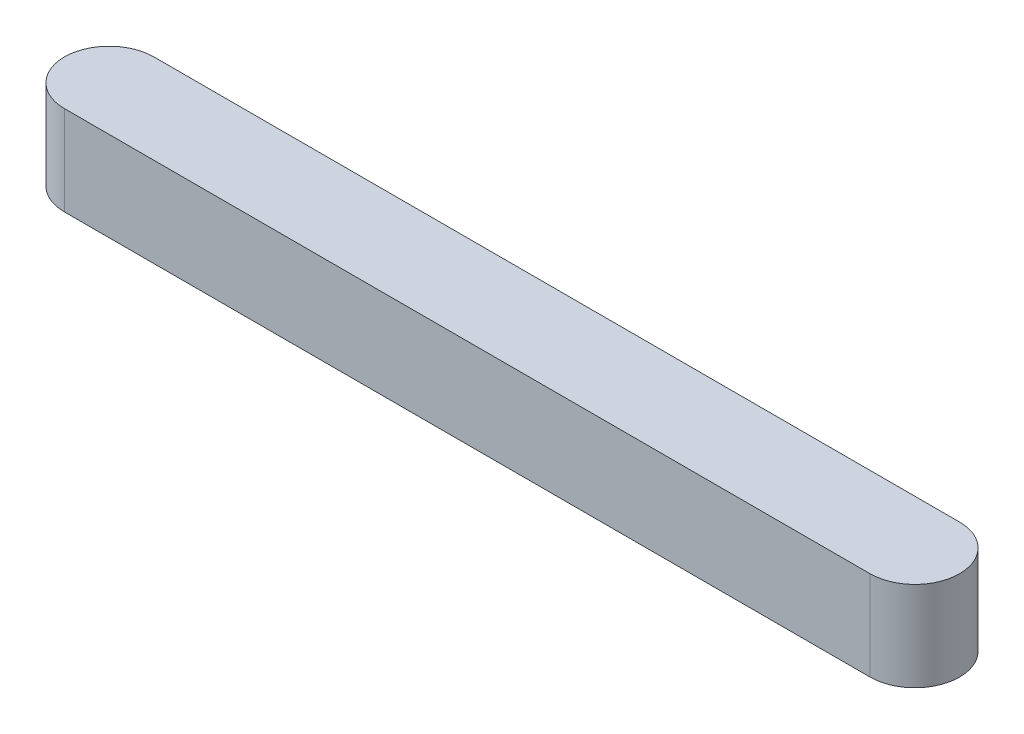
from build123d import *

# Parameters (mm, degrees)
BOSS_EXTRUDE1_DEPTH = 2


with BuildPart() as part:
    # Sketch1 → Boss-Extrude1 (new body)
    with BuildSketch(Plane(origin=(0, 0, 0), x_dir=(1, 0, 0), z_dir=(0, 1, 0))):
        with BuildLine():
            Line((-9, 1), (9, 1))
            ThreePointArc((9, 1), (10, 0), (9, -1))
            Line((9, -1), (-9, -1))
            ThreePointArc((-9, -1), (-10, 0), (-9, 1))
        make_face()
    extrude(amount=BOSS_EXTRUDE1_DEPTH)


solid = part.part
